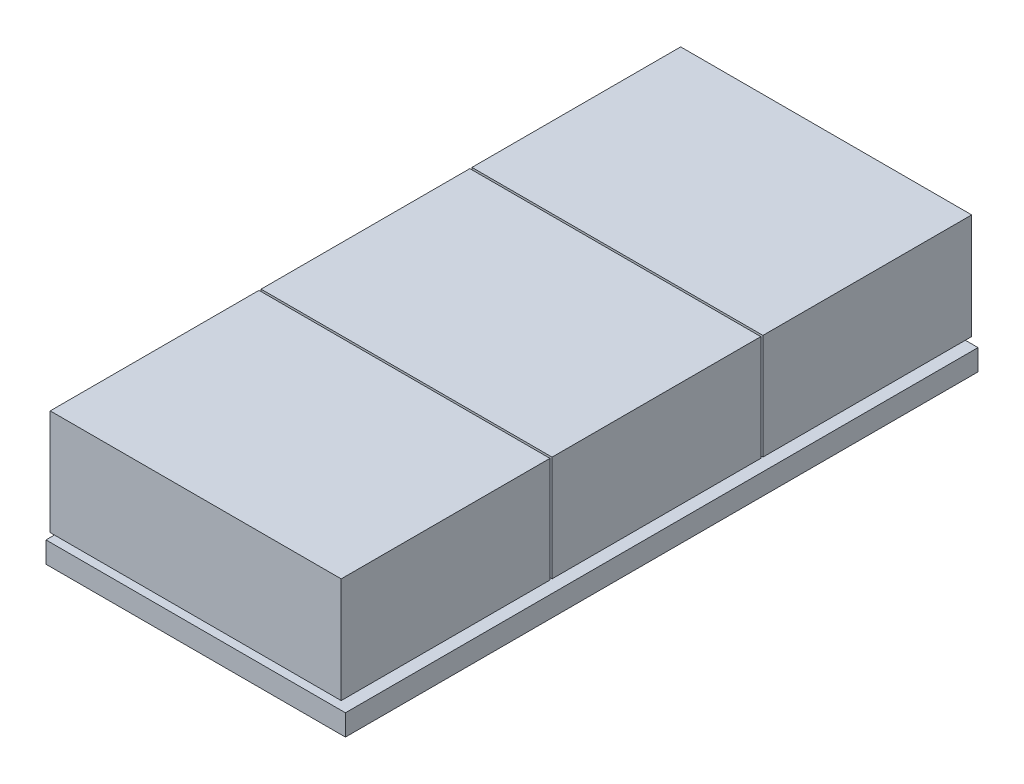
from build123d import *

# Parameters (mm, degrees)
SKETCH1_W           = 71
SKETCH1_H           = 150
BOSS_EXTRUDE1_DEPTH = 5
SKETCH2_W           = 65
SKETCH2_H           = 45
BOSS_EXTRUDE3_DEPTH = 2
LPATTERN1_COUNT     = 3
LPATTERN1_PITCH     = 50
SKETCH3_W           = 69
SKETCH3_H           = 49.5
BOSS_EXTRUDE8_DEPTH = 25
LPATTERN5_COUNT     = 3
LPATTERN5_PITCH     = 50


with BuildPart() as part:
    # Sketch1 → Boss-Extrude1 (new body)
    with BuildSketch(Plane(origin=(0, 0, 0), x_dir=(1, 0, 0), z_dir=(0, 1, 0))):
        Rectangle(SKETCH1_W, SKETCH1_H)
    extrude(amount=BOSS_EXTRUDE1_DEPTH)

    # Sketch2 → Boss-Extrude3 (add)
    with BuildSketch(Plane(origin=(0, 5, 0), x_dir=(1, 0, 0), z_dir=(0, 1, 0))):
        with Locations((0, -50)):
            Rectangle(SKETCH2_W, SKETCH2_H)
    boss_extrude3 = extrude(amount=BOSS_EXTRUDE3_DEPTH)

    # LPattern1: Boss-Extrude3 ×3
    with Locations(*[(0, 0, -i * LPATTERN1_PITCH) for i in range(1, LPATTERN1_COUNT)]):
        add(boss_extrude3)

    # Sketch3 → Boss-Extrude8 (add)
    with BuildSketch(Plane(origin=(0, 7, 0), x_dir=(1, 0, 0), z_dir=(0, 1, 0))):
        with Locations((0, -50.25)):
            Rectangle(SKETCH3_W, SKETCH3_H)
    boss_extrude8 = extrude(amount=BOSS_EXTRUDE8_DEPTH)

    # LPattern5: Boss-Extrude8 ×3
    with Locations(*[(0, 0, -i * LPATTERN5_PITCH) for i in range(1, LPATTERN5_COUNT)]):
        add(boss_extrude8)


solid = part.part
